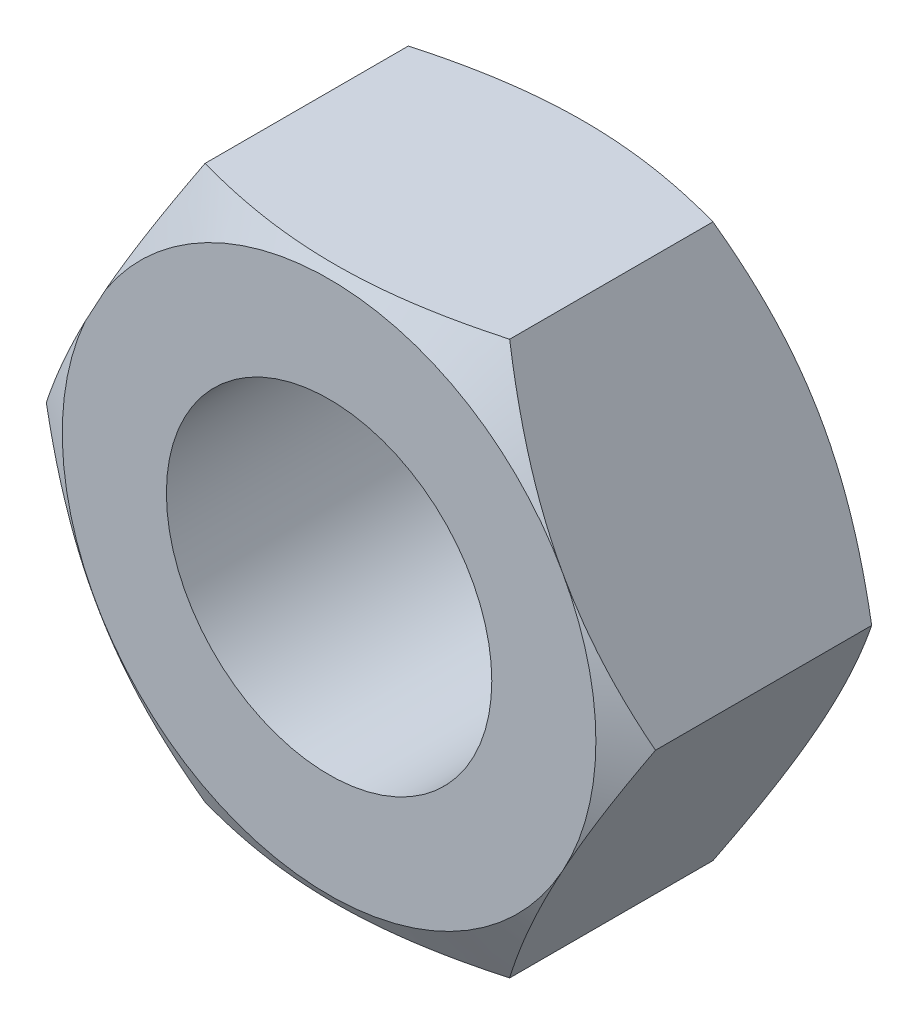
from build123d import *

# Parameters (mm, degrees)
BOSS_EXTRUDE1_DEPTH = 8
SKETCH2_OUTSIDE_W   = 60.666
SKETCH2_OUTSIDE_H   = 58.946
SKETCH2_OUTSIDE_R   = 8.199202844
CUT_EXTRUDE1_DEPTH  = 10
CUT_EXTRUDE1_TAPER  = 60
SKETCH3_OUTSIDE_W   = 29.488
SKETCH3_OUTSIDE_H   = 27.768
SKETCH3_OUTSIDE_R   = 8.172152793
CUT_EXTRUDE2_DEPTH  = 1
CUT_EXTRUDE2_TAPER  = 60
SKETCH4_R           = 5
CUT_EXTRUDE3_DEPTH  = 8


with BuildPart() as part:
    # Sketch1 → Boss-Extrude1 (new body)
    with BuildSketch(Plane.XY):
        Polygon((9.359699903, 0), (4.68, 8.5), (-4.68, 8.5), (-9.36, -0.105997779), (-4.68, -8.5), (4.68, -8.5), align=None)
    extrude(amount=BOSS_EXTRUDE1_DEPTH)

    # Sketch2 outside → Cut-Extrude1 (cut)
    with BuildSketch(Plane.XY.offset(8)):
        Rectangle(SKETCH2_OUTSIDE_W, SKETCH2_OUTSIDE_H)
        Circle(SKETCH2_OUTSIDE_R, mode=Mode.SUBTRACT)
    extrude(amount=-CUT_EXTRUDE1_DEPTH, taper=CUT_EXTRUDE1_TAPER, mode=Mode.SUBTRACT)

    # Sketch3 outside → Cut-Extrude2 (cut)
    with BuildSketch(Plane(origin=(0, 0, 0), x_dir=(-1, 0, 0), z_dir=(0, 0, -1))):
        Rectangle(SKETCH3_OUTSIDE_W, SKETCH3_OUTSIDE_H)
        Circle(SKETCH3_OUTSIDE_R, mode=Mode.SUBTRACT)
    extrude(amount=-CUT_EXTRUDE2_DEPTH, taper=CUT_EXTRUDE2_TAPER, mode=Mode.SUBTRACT)

    # Sketch4 → Cut-Extrude3 (cut)
    with BuildSketch(Plane.XY.offset(8)):
        Circle(SKETCH4_R)
    extrude(amount=-CUT_EXTRUDE3_DEPTH, mode=Mode.SUBTRACT)


solid = part.part
